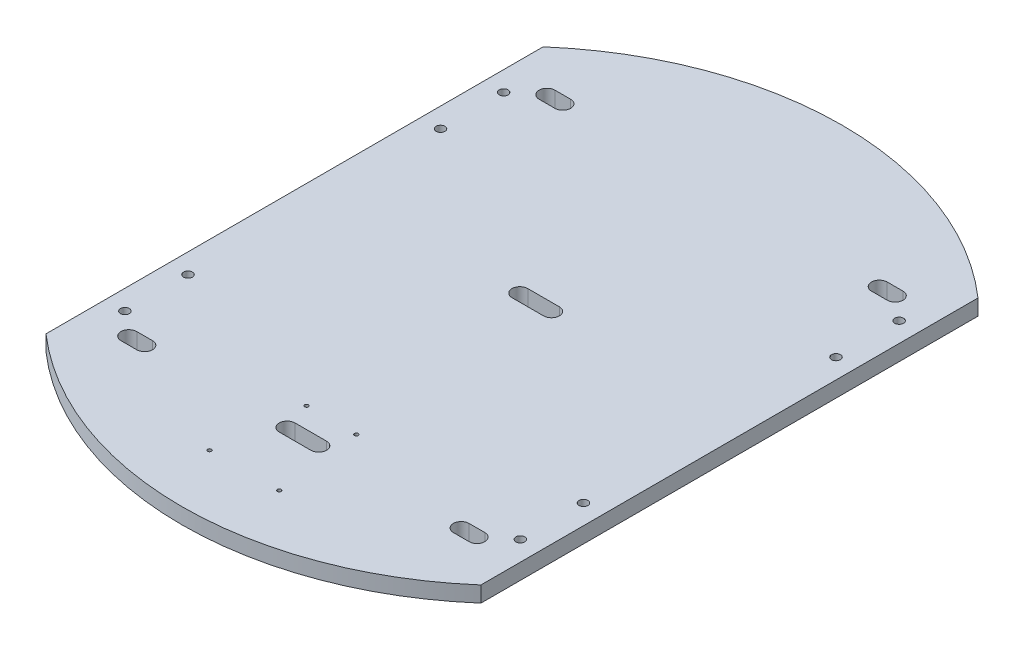
from build123d import *

# Parameters (mm, degrees)
SKETCH1_R           = 1.5
SKETCH1_R_2         = 3.5687
BOSS_EXTRUDE1_DEPTH = 12.7


with BuildPart() as part:
    # Sketch1 → Boss-Extrude1 (new body)
    with BuildSketch(Plane(origin=(0, 0, 0), x_dir=(1, 0, 0), z_dir=(0, 1, 0))):
        with BuildLine():
            Line((175, -200), (175, 200))
            ThreePointArc((175, 200), (0, 265.753645318), (-175, 200))
            Line((-175, 200), (-175, -200))
            ThreePointArc((-175, -200), (0, -265.753645318), (175, -200))
        make_face()
        with Locations((20, -145.3)):
            Circle(SKETCH1_R, mode=Mode.SUBTRACT)
        with Locations((-20, -145.3)):
            Circle(SKETCH1_R, mode=Mode.SUBTRACT)
        with Locations((28, -215.3)):
            Circle(SKETCH1_R, mode=Mode.SUBTRACT)
        with Locations((-28, -215.3)):
            Circle(SKETCH1_R, mode=Mode.SUBTRACT)
        with Locations((-159.12, -101.6)):
            Circle(SKETCH1_R_2, mode=Mode.SUBTRACT)
        with Locations((-159.12, -152.4)):
            Circle(SKETCH1_R_2, mode=Mode.SUBTRACT)
        with Locations((-159.12, 152.4)):
            Circle(SKETCH1_R_2, mode=Mode.SUBTRACT)
        with Locations((-159.12, 101.6)):
            Circle(SKETCH1_R_2, mode=Mode.SUBTRACT)
        with Locations((159.12, -152.4)):
            Circle(SKETCH1_R_2, mode=Mode.SUBTRACT)
        with Locations((159.12, -101.6)):
            Circle(SKETCH1_R_2, mode=Mode.SUBTRACT)
        with Locations((159.12, 101.6)):
            Circle(SKETCH1_R_2, mode=Mode.SUBTRACT)
        with Locations((159.12, 152.4)):
            Circle(SKETCH1_R_2, mode=Mode.SUBTRACT)
        with BuildLine():
            Line((-12.7, -161.9), (12.7, -161.9))
            ThreePointArc((12.7, -161.9), (19.05, -168.25), (12.7, -174.6))
            Line((12.7, -174.6), (-12.7, -174.6))
            ThreePointArc((-12.7, -174.6), (-19.05, -168.25), (-12.7, -161.9))
        make_face(mode=Mode.SUBTRACT)
        with BuildLine():
            Line((-140.07, -161.9), (-127.37, -161.9))
            ThreePointArc((-127.37, -161.9), (-121.02, -168.25), (-127.37, -174.6))
            Line((-127.37, -174.6), (-140.07, -174.6))
            ThreePointArc((-140.07, -174.6), (-146.42, -168.25), (-140.07, -161.9))
        make_face(mode=Mode.SUBTRACT)
        with BuildLine():
            Line((127.37, -161.9), (140.07, -161.9))
            ThreePointArc((140.07, -161.9), (146.42, -168.25), (140.07, -174.6))
            Line((140.07, -174.6), (127.37, -174.6))
            ThreePointArc((127.37, -174.6), (121.02, -168.25), (127.37, -161.9))
        make_face(mode=Mode.SUBTRACT)
        with BuildLine():
            Line((-140.07, 174.6), (-127.37, 174.6))
            ThreePointArc((-127.37, 174.6), (-121.02, 168.25), (-127.37, 161.9))
            Line((-127.37, 161.9), (-140.07, 161.9))
            ThreePointArc((-140.07, 161.9), (-146.42, 168.25), (-140.07, 174.6))
        make_face(mode=Mode.SUBTRACT)
        with BuildLine():
            Line((127.37, 174.6), (140.07, 174.6))
            ThreePointArc((140.07, 174.6), (146.42, 168.25), (140.07, 161.9))
            Line((140.07, 161.9), (127.37, 161.9))
            ThreePointArc((127.37, 161.9), (121.02, 168.25), (127.37, 174.6))
        make_face(mode=Mode.SUBTRACT)
        with BuildLine():
            Line((-12.7, 25.4), (12.7, 25.4))
            ThreePointArc((12.7, 25.4), (19.05, 19.05), (12.7, 12.7))
            Line((12.7, 12.7), (-12.7, 12.7))
            ThreePointArc((-12.7, 12.7), (-19.05, 19.05), (-12.7, 25.4))
        make_face(mode=Mode.SUBTRACT)
    extrude(amount=BOSS_EXTRUDE1_DEPTH)


solid = part.part
